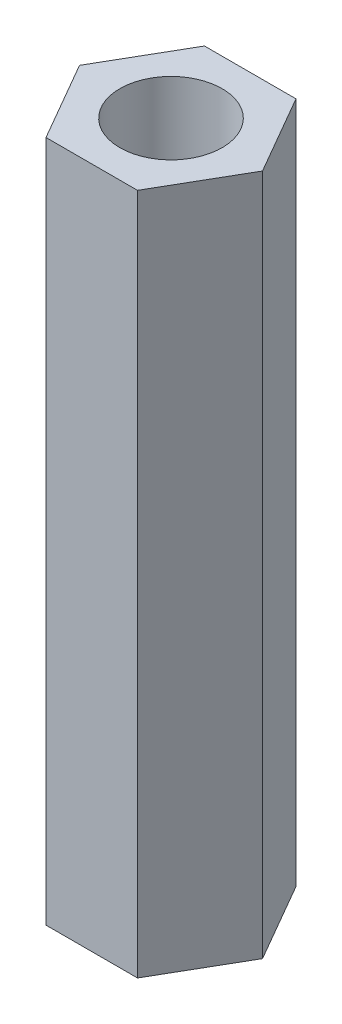
from build123d import *

# Parameters (mm, degrees)
SKETCH1_R           = 1.5
BOSS_EXTRUDE1_DEPTH = 20


with BuildPart() as part:
    # Sketch1 → Boss-Extrude1 (new body)
    with BuildSketch(Plane(origin=(0, 0, 0), x_dir=(1, 0, 0), z_dir=(0, 1, 0))):
        Polygon((1.341379, 2.32333658), (2.682757999, 0), (1.341379, -2.32333658), (-1.341379, -2.32333658), (-2.682757999, 0), (-1.341379, 2.32333658), align=None)
        Circle(SKETCH1_R, mode=Mode.SUBTRACT)
    extrude(amount=BOSS_EXTRUDE1_DEPTH)


solid = part.part
